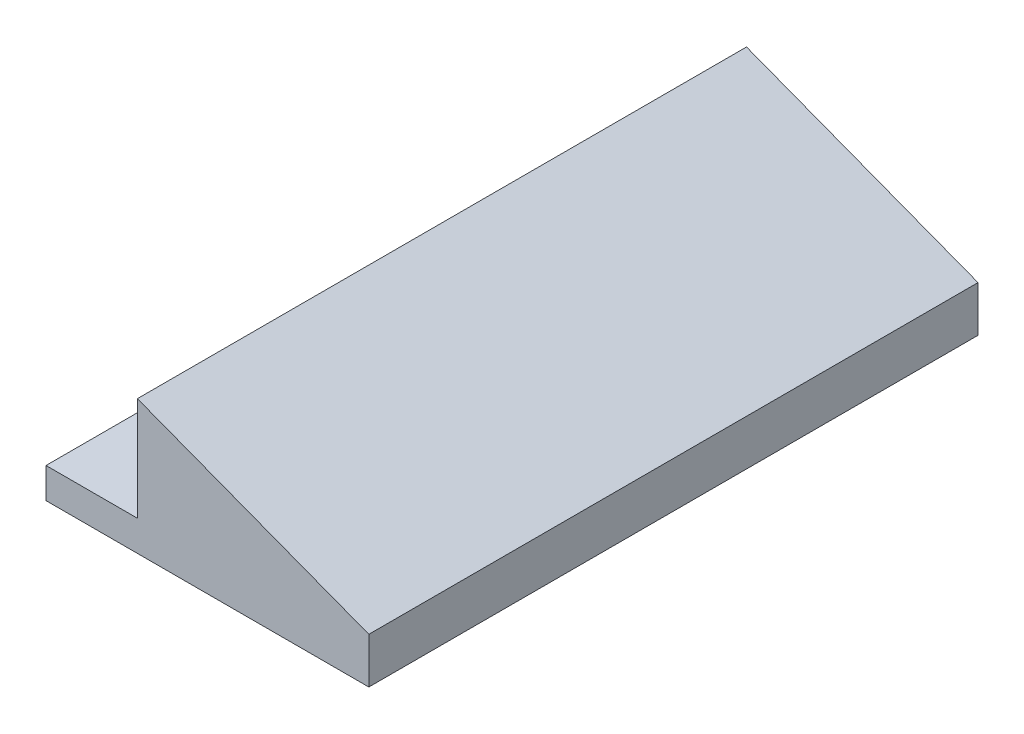
from build123d import *

# Parameters (mm, degrees)
SALIENTE_EXTRUIR1_DEPTH = 100
CROQUIS2_R              = 2
CORTAR_EXTRUIR1_DEPTH   = 100


with BuildPart() as part:
    # Croquis1 → Saliente-Extruir1 (new body)
    with BuildSketch(Plane.XY):
        Polygon((0, 0), (-15, 0), (-15, 5), (0, 5), (0, 22), (38, 7.5), (38, 0), align=None)
    extrude(amount=SALIENTE_EXTRUIR1_DEPTH)

    # Croquis2 → Cortar-Extruir1 (cut)
    with BuildSketch(Plane(origin=(0, 5, 0), x_dir=(1, 0, 0), z_dir=(0, 1, 0))):
        with Locations((-7.5, -80)):
            Circle(CROQUIS2_R)
        with Locations((-7.5, -20)):
            Circle(CROQUIS2_R)
    extrude(amount=-CORTAR_EXTRUIR1_DEPTH, mode=Mode.SUBTRACT)


solid = part.part
